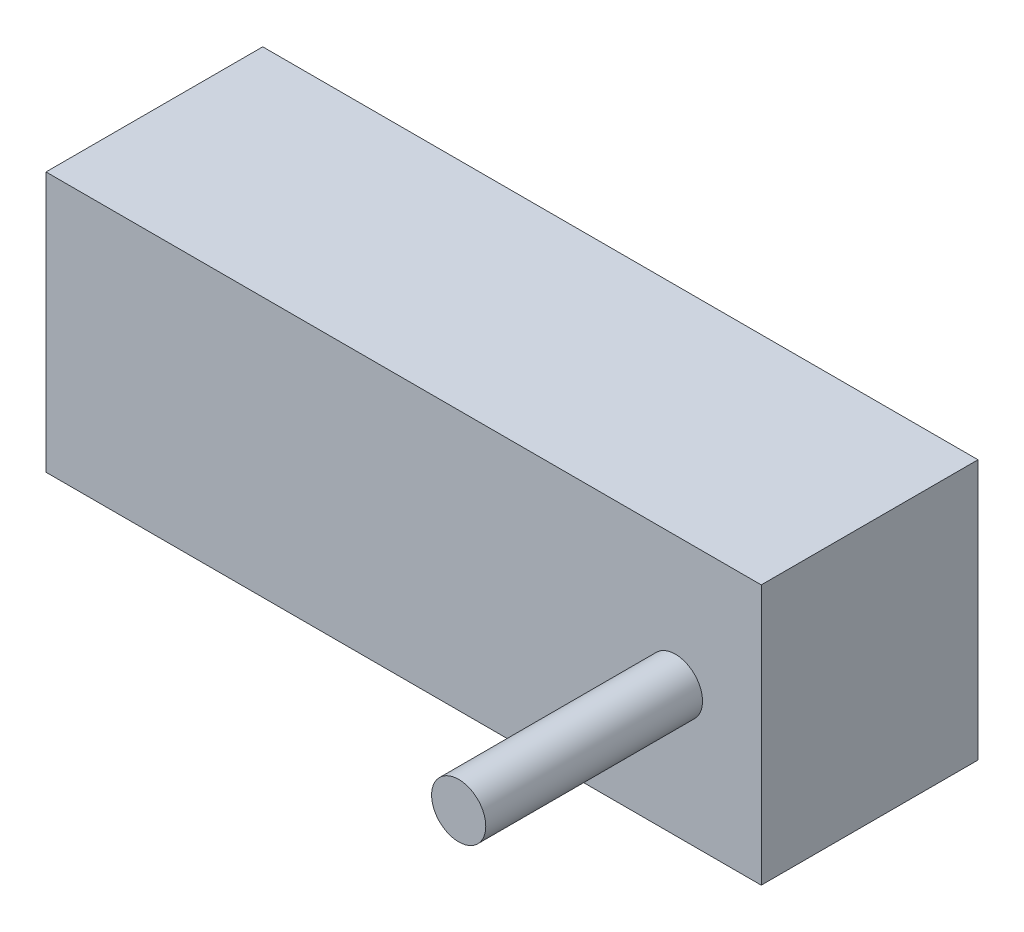
from build123d import *

# Parameters (mm, degrees)
SKETCH1_R           = 1.25
BOSS_EXTRUDE2_DEPTH = 20
SKETCH1_5_W         = 33
SKETCH1_5_H         = 12
SKETCH1_5_R         = 1.25
BOSS_EXTRUDE3_DEPTH = 10


with BuildPart() as part:
    # Sketch1 → Boss-Extrude2 (new body)
    with BuildSketch(Plane.XY):
        with Locations((29.04, 6)):
            Circle(SKETCH1_R)
    extrude(amount=BOSS_EXTRUDE2_DEPTH)

    # Sketch1_5 → Boss-Extrude3 (add)
    with BuildSketch(Plane.XY):
        with Locations((16.5, 6)):
            Rectangle(SKETCH1_5_W, SKETCH1_5_H)
        with Locations((29.04, 6)):
            Circle(SKETCH1_5_R, mode=Mode.SUBTRACT)
    extrude(amount=BOSS_EXTRUDE3_DEPTH)


solid = part.part
